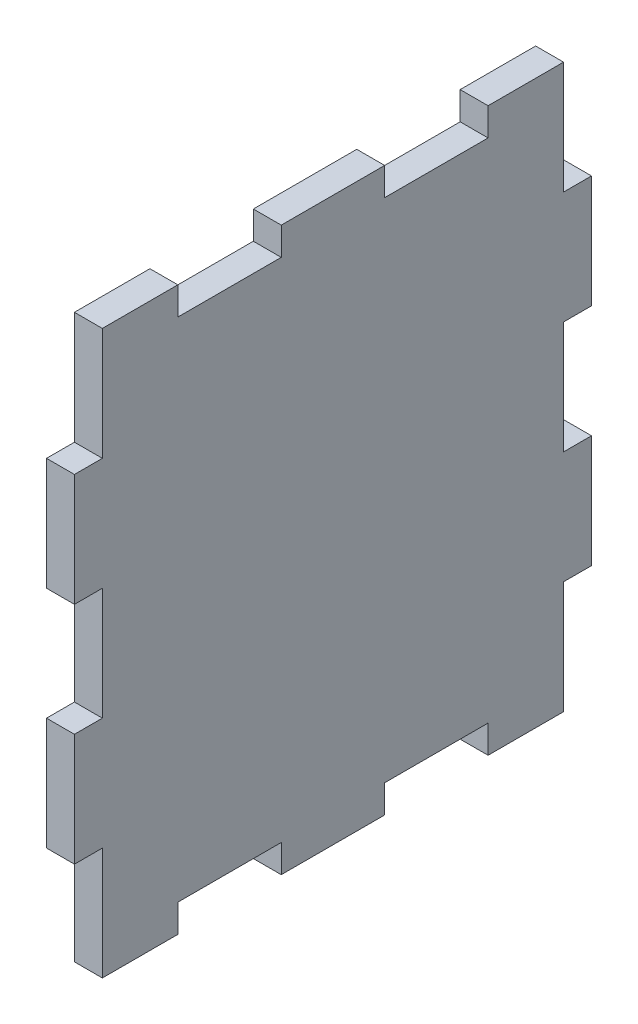
from build123d import *

# Parameters (mm, degrees)
BOSS_EXTRUDE1_DEPTH = 2.7


with BuildPart() as part:
    # Sketch1 → Boss-Extrude1 (new body)
    with BuildSketch(Plane(origin=(0, 0, 0), x_dir=(0, 0, -1), z_dir=(1, 0, 0))):
        Polygon((25, 5.44), (25, 16.32), (22.3, 16.32), (22.3, 27.2), (15, 27.2), (15, 24.5), (5, 24.5), (5, 27.2), (-5, 27.2), (-5, 24.5), (-15, 24.5), (-15, 27.2), (-22.3, 27.2), (-22.3, 16.32), (-25, 16.32), (-25, 5.44), (-22.3, 5.44), (-22.3, -5.44), (-25, -5.44), (-25, -16.32), (-22.3, -16.32), (-22.3, -27.2), (-15, -27.2), (-15, -24.5), (-5, -24.5), (-5, -27.2), (5, -27.2), (5, -24.5), (15, -24.5), (15, -27.2), (22.3, -27.2), (22.3, -16.32), (25, -16.32), (25, -5.44), (22.3, -5.44), (22.3, 5.44), align=None)
    extrude(amount=BOSS_EXTRUDE1_DEPTH)


solid = part.part
